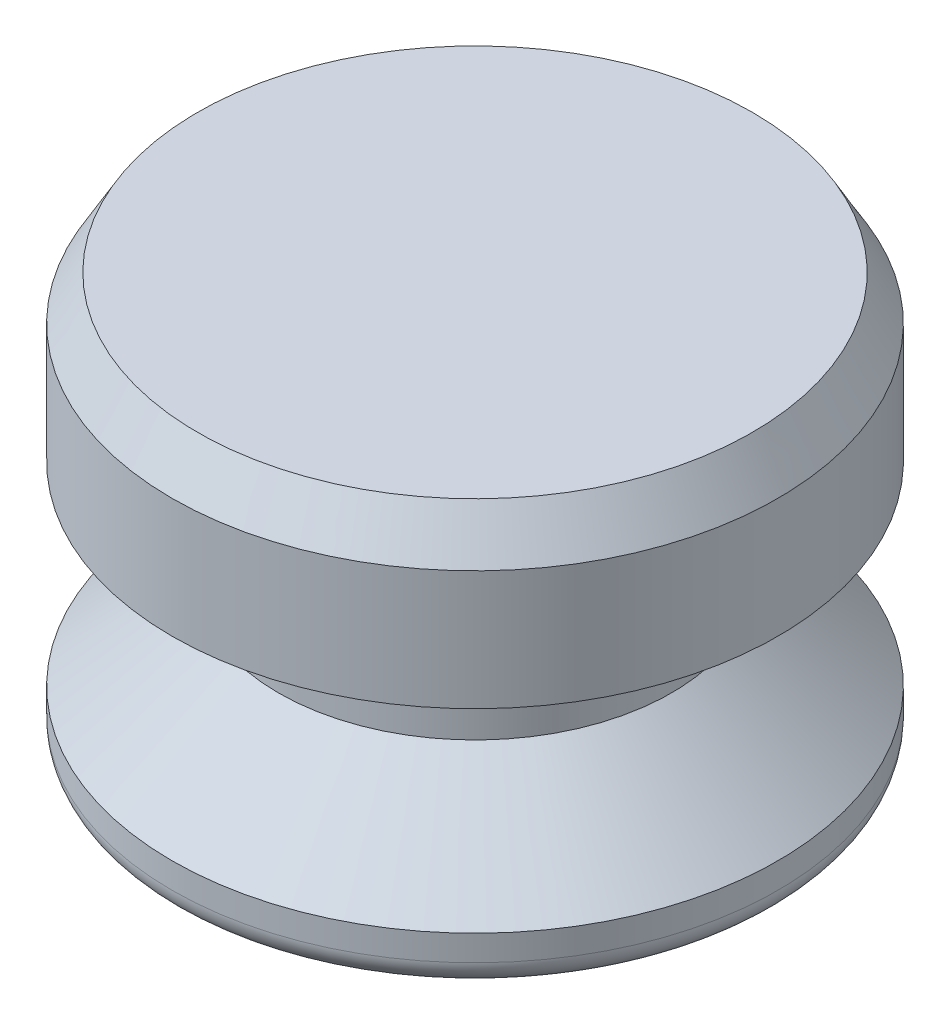
from build123d import *

# Parameters (mm, degrees)
FILLET1_R      = 0.79375
CHAMFER1_SIZE  = 0.79375
CHAMFER1_SIZE2 = 1.374815329


with BuildPart() as part:
    # Sketch1 → Revolve1 (revolve)
    with BuildSketch(Plane.XY):
        Polygon((0, 0), (-9.398, 0), (-9.398, 1.5875), (-6.096, 4.445), (-6.096, 7.62), (-9.398, 7.62), (-9.398, 12.7), (0, 12.7), align=None)
    revolve(axis=Axis((0, 0, 0), (0, 1, 0)))

    # Fillet1
    fillet1_edges = [part.edges().sort_by_distance(p)[0] for p in [
        (9.398, 0, 0),
    ]]
    fillet(fillet1_edges, radius=FILLET1_R)

    # Chamfer1
    chamfer1_edges = [part.edges().sort_by_distance(p)[0] for p in [
        (9.398, 12.7, 0),
    ]]
    chamfer1_side = [part.faces().sort_by_distance(p)[0] for p in [
        (0, 12.7, 0),
    ]]
    chamfer(chamfer1_edges, length=CHAMFER1_SIZE, length2=CHAMFER1_SIZE2, reference=chamfer1_side[0])


solid = part.part
